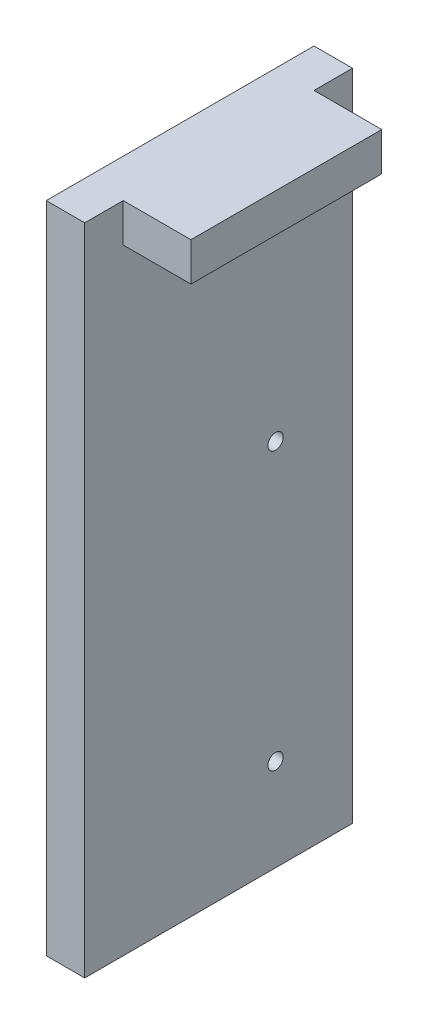
from build123d import *

# Parameters (mm, degrees)
SKETCH1_W           = 11.049
SKETCH1_H           = 26.9875
BOSS_EXTRUDE1_DEPTH = 1.5875
SKETCH2_W           = 7.874
SKETCH2_H           = 1.5875
BOSS_EXTRUDE2_DEPTH = 2.794
CUT_EXTRUDE1_REACH  = 6.381
SKETCH3_R           = 0.3175


with BuildPart() as part:
    # Sketch1 → Boss-Extrude1 (new body)
    with BuildSketch(Plane(origin=(0, 0, 0), x_dir=(0, 0, -1), z_dir=(1, 0, 0))):
        Rectangle(SKETCH1_W, SKETCH1_H)
    extrude(amount=BOSS_EXTRUDE1_DEPTH)

    # Sketch2 → Boss-Extrude2 (add)
    with BuildSketch(Plane(origin=(1.5875, 0, 0), x_dir=(0, 0, -1), z_dir=(1, 0, 0))):
        with Locations((0, 12.7)):
            Rectangle(SKETCH2_W, SKETCH2_H)
    extrude(amount=BOSS_EXTRUDE2_DEPTH)

    # Sketch3 → Cut-Extrude1 (cut, up to next)
    with BuildSketch(Plane.ZY, mode=Mode.PRIVATE) as cut_extrude1_sk1:
        with Locations((-2.3495, 1.74625)):
            Circle(SKETCH3_R)
    cut_extrude1_tool1 = extrude(cut_extrude1_sk1.sketch, amount=-CUT_EXTRUDE1_REACH, mode=Mode.PRIVATE) & part.part
    add(cut_extrude1_tool1.solids().sort_by_distance((0, 1.74625, -2.3495))[0], mode=Mode.SUBTRACT)
    # Sketch3 → Cut-Extrude1 (cut, up to next)
    with BuildSketch(Plane.ZY, mode=Mode.PRIVATE) as cut_extrude1_sk2:
        with Locations((-2.3495, -9.68375)):
            Circle(SKETCH3_R)
    cut_extrude1_tool2 = extrude(cut_extrude1_sk2.sketch, amount=-CUT_EXTRUDE1_REACH, mode=Mode.PRIVATE) & part.part
    add(cut_extrude1_tool2.solids().sort_by_distance((0, -9.68375, -2.3495))[0], mode=Mode.SUBTRACT)


solid = part.part
